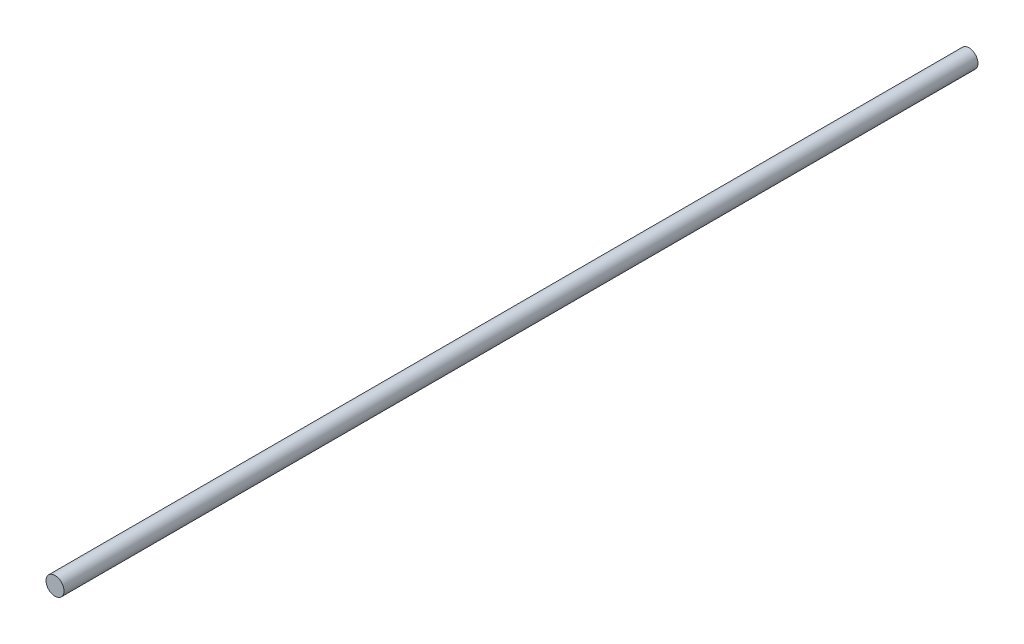
from build123d import *

# Parameters (mm, degrees)
SKETCH1_R      = 4.7625
EXTRUDE1_DEPTH = 241.3


with BuildPart() as part:
    # Sketch1 → Extrude1 (new body, symmetric)
    with BuildSketch(Plane.XY):
        with Locations((-356.05, 162.7)):
            Circle(SKETCH1_R)
    extrude(amount=EXTRUDE1_DEPTH, both=True)


solid = part.part
